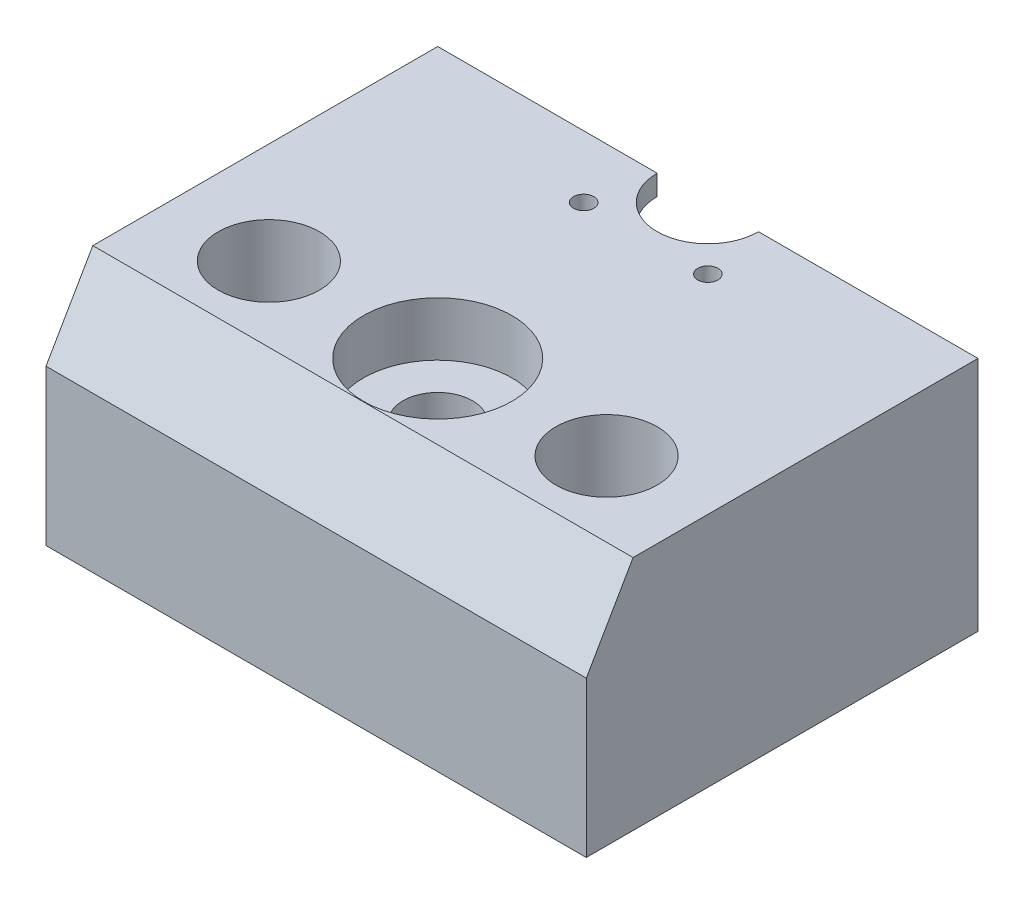
from build123d import *

# Parameters (mm, degrees)
BOSS_EXTRUDE1_DEPTH = 35
SKETCH2_R           = 7.5
SKETCH2_R_2         = 5.15
CUT_EXTRUDE1_DEPTH  = 36
BOSS_EXTRUDE2_DEPTH = 3
SKETCH6_R           = 1.5
CUT_EXTRUDE3_DEPTH  = 4
CHAMFER1_SIZE       = 12
CHAMFER1_SIZE2      = 6.92820323
SKETCH7_R           = 11
CUT_EXTRUDE4_DEPTH  = 8


with BuildPart() as part:
    # Sketch1 → Boss-Extrude1 (new body)
    with BuildSketch(Plane(origin=(0, 0, 0), x_dir=(1, 0, 0), z_dir=(0, 1, 0))):
        with BuildLine():
            Line((19.15, 0), (40, 0))
            Line((40, 0), (40, -58))
            Line((40, -58), (-40, -58))
            Line((-40, -58), (-40, 0))
            Line((-40, 0), (-19.15, 0))
            ThreePointArc((-19.15, 0), (0, -19.15), (19.15, 0))
        make_face()
    extrude(amount=BOSS_EXTRUDE1_DEPTH)

    # Sketch2 → Cut-Extrude1 (cut, through all)
    with BuildSketch(Plane(origin=(0, 35, 0), x_dir=(1, 0, 0), z_dir=(0, 1, 0))):
        with Locations((-25, -40)):
            Circle(SKETCH2_R)
        with Locations((25, -40)):
            Circle(SKETCH2_R)
        with Locations((0, -40)):
            Circle(SKETCH2_R_2)
    extrude(amount=-CUT_EXTRUDE1_DEPTH, mode=Mode.SUBTRACT)

    # Sketch5 → Boss-Extrude2 (add)
    with BuildSketch(Plane(origin=(0, 35, 0), x_dir=(1, 0, 0), z_dir=(0, 1, 0))):
        with BuildLine():
            Line((-19.15, 0), (-7.5, 0))
            ThreePointArc((-7.5, 0), (0, -7.5), (7.5, 0))
            Line((7.5, 0), (19.15, 0))
            ThreePointArc((19.15, 0), (0, -19.15), (-19.15, 0))
        make_face()
    extrude(amount=-BOSS_EXTRUDE2_DEPTH)

    # Sketch6 → Cut-Extrude3 (cut, through all)
    with BuildSketch(Plane.XZ.offset(-32)):
        with Locations((9.192388155, 9.192388155)):
            Circle(SKETCH6_R)
        with Locations((-9.192388155, 9.192388155)):
            Circle(SKETCH6_R)
    extrude(amount=-CUT_EXTRUDE3_DEPTH, mode=Mode.SUBTRACT)

    # Chamfer1
    chamfer1_edges = [part.edges().sort_by_distance(p)[0] for p in [
        (0, 35, 58),
    ]]
    chamfer1_side = [part.faces().sort_by_distance(p)[0] for p in [
        (0, 17.5, 58),
    ]]
    chamfer(chamfer1_edges, length=CHAMFER1_SIZE, length2=CHAMFER1_SIZE2, reference=chamfer1_side[0])

    # Sketch7 → Cut-Extrude4 (cut)
    with BuildSketch(Plane(origin=(0, 35, 0), x_dir=(1, 0, 0), z_dir=(0, 1, 0))):
        with Locations((0, -40)):
            Circle(SKETCH7_R)
    extrude(amount=-CUT_EXTRUDE4_DEPTH, mode=Mode.SUBTRACT)


solid = part.part
